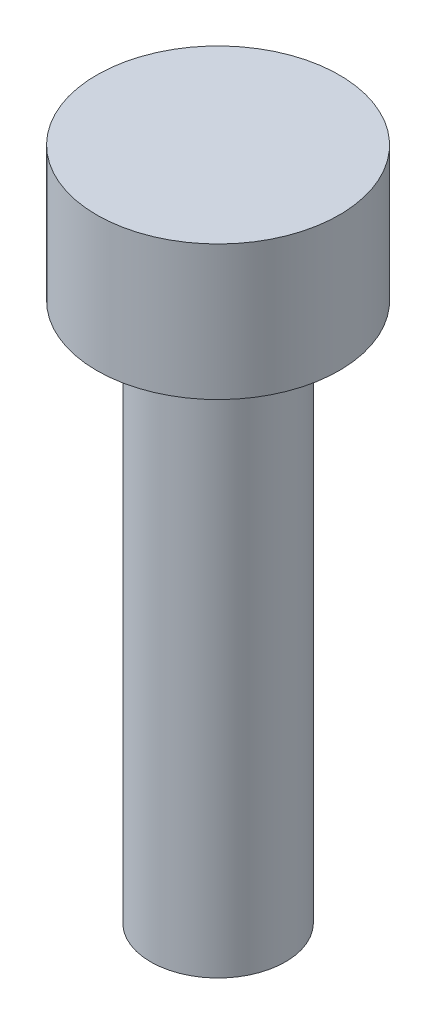
from build123d import *

# Parameters (mm, degrees)
SKETCH1_R           = 1.5
BOSS_EXTRUDE1_DEPTH = 12
SKETCH2_R           = 2.7
BOSS_EXTRUDE2_DEPTH = 3


with BuildPart() as part:
    # Sketch1 → Boss-Extrude1 (new body)
    with BuildSketch(Plane(origin=(0, 0, 0), x_dir=(1, 0, 0), z_dir=(0, 1, 0))):
        Circle(SKETCH1_R)
    extrude(amount=BOSS_EXTRUDE1_DEPTH)

    # Sketch2 → Boss-Extrude2 (add)
    with BuildSketch(Plane(origin=(0, 12, 0), x_dir=(1, 0, 0), z_dir=(0, 1, 0))):
        Circle(SKETCH2_R)
    extrude(amount=BOSS_EXTRUDE2_DEPTH)


solid = part.part
